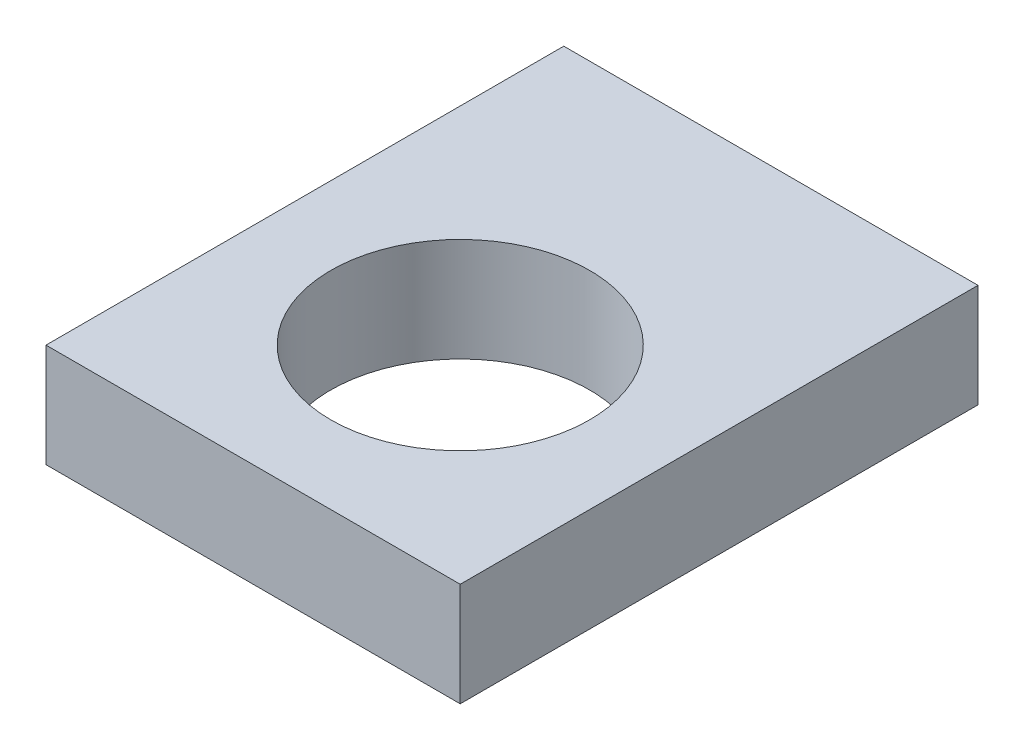
from build123d import *

# Parameters (mm, degrees)
SKETCH1_W           = 50.8
SKETCH1_H           = 63.5
BOSS_EXTRUDE1_DEPTH = 6.35
SKETCH2_R           = 15.875
CUT_EXTRUDE1_DEPTH  = 13.7
SKETCH3_R           = 3.175
CUT_EXTRUDE2_DEPTH  = 12.7


with BuildPart() as part:
    # Sketch1 → Boss-Extrude1 (new body, symmetric)
    with BuildSketch(Plane(origin=(0, 0, 0), x_dir=(1, 0, 0), z_dir=(0, 1, 0))):
        with Locations((0, 6.35)):
            Rectangle(SKETCH1_W, SKETCH1_H)
    extrude(amount=BOSS_EXTRUDE1_DEPTH, both=True)

    # Sketch2 → Cut-Extrude1 (cut, through all)
    with BuildSketch(Plane(origin=(0, 6.35, 0), x_dir=(1, 0, 0), z_dir=(0, 1, 0))):
        Circle(SKETCH2_R)
    extrude(amount=-CUT_EXTRUDE1_DEPTH, mode=Mode.SUBTRACT)

    # Sketch3 → Cut-Extrude2 (cut)
    with BuildSketch(Plane(origin=(0, 0, -38.1), x_dir=(-1, 0, 0), z_dir=(0, 0, -1))):
        with Locations((-15.875, 0)):
            Circle(SKETCH3_R)
        with Locations((15.875, 0)):
            Circle(SKETCH3_R)
    extrude(amount=-CUT_EXTRUDE2_DEPTH, mode=Mode.SUBTRACT)


solid = part.part
